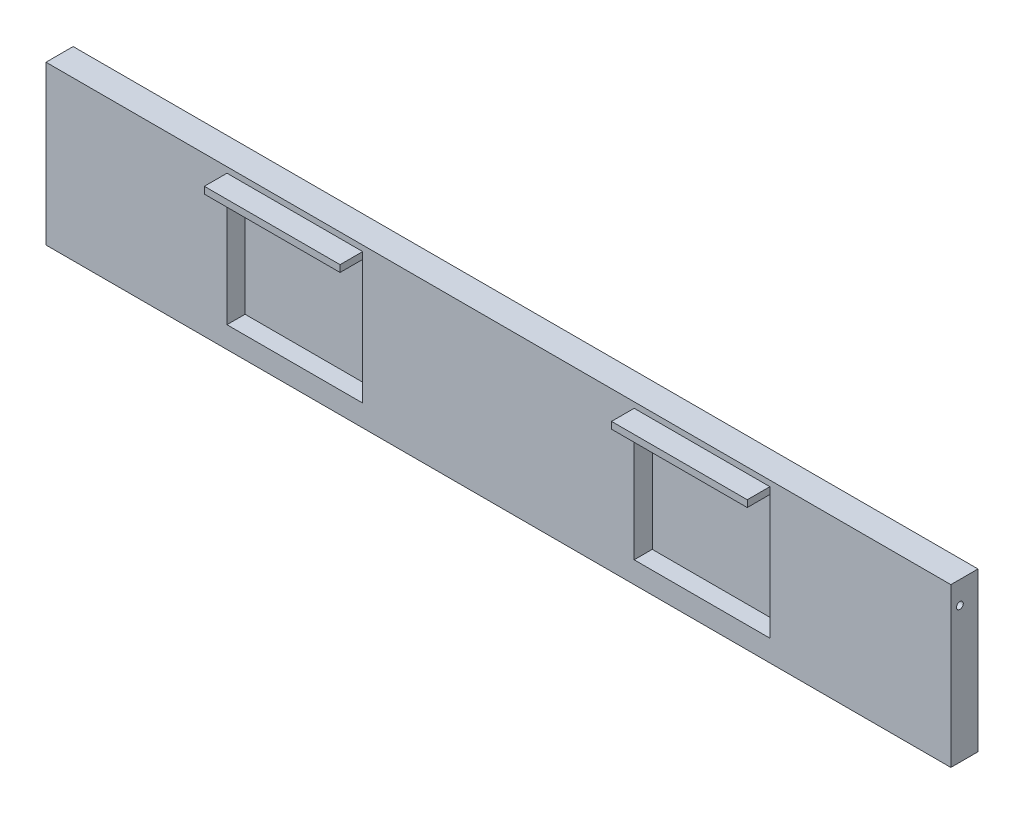
from build123d import *

# Parameters (mm, degrees)
SKETCH1_W           = 400
SKETCH1_H           = 70
BOSS_EXTRUDE1_DEPTH = 12
SKETCH3_W           = 60
SKETCH3_H           = 55
CUT_EXTRUDE1_DEPTH  = 8
SKETCH4_R           = 1.5
CUT_EXTRUDE2_DEPTH  = 401
SKETCH5_W           = 60
SKETCH5_H           = 3
BOSS_EXTRUDE2_DEPTH = 10


with BuildPart() as part:
    # Sketch1 → Boss-Extrude1 (new body)
    with BuildSketch(Plane.XY):
        Rectangle(SKETCH1_W, SKETCH1_H)
    extrude(amount=BOSS_EXTRUDE1_DEPTH)

    # Sketch3 → Cut-Extrude1 (cut)
    with BuildSketch(Plane.XY.offset(12)):
        with Locations((-90, 2)):
            Rectangle(SKETCH3_W, SKETCH3_H)
        with Locations((90, 2)):
            Rectangle(SKETCH3_W, SKETCH3_H)
    extrude(amount=-CUT_EXTRUDE1_DEPTH, mode=Mode.SUBTRACT)

    # Sketch4 → Cut-Extrude2 (cut, through all)
    with BuildSketch(Plane.ZY.offset(200)):
        with Locations((8, 25)):
            Circle(SKETCH4_R)
    extrude(amount=-CUT_EXTRUDE2_DEPTH, mode=Mode.SUBTRACT)

    # Sketch5 → Boss-Extrude2 (add)
    with BuildSketch(Plane.XY.offset(12)):
        with Locations((-90, 31)):
            Rectangle(SKETCH5_W, SKETCH5_H)
        with Locations((90, 31)):
            Rectangle(SKETCH5_W, SKETCH5_H)
    extrude(amount=BOSS_EXTRUDE2_DEPTH)


solid = part.part
